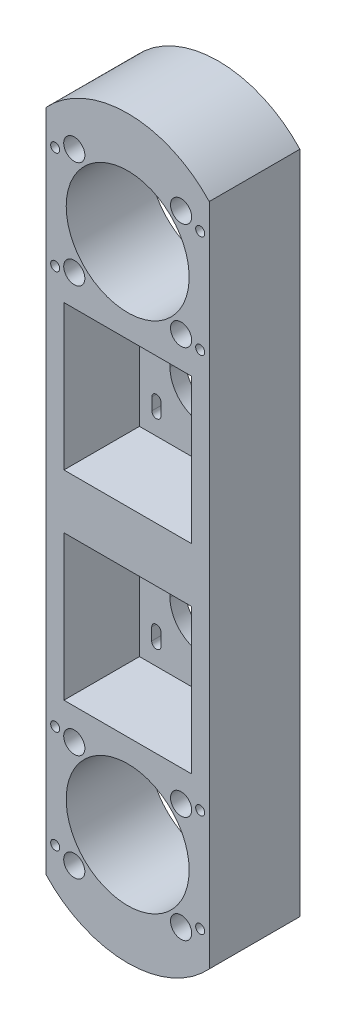
from build123d import *

# Parameters (mm, degrees)
SKETCH_1_W                = 54
SKETCH_1_H                = 220
EXTRUDE_1_DEPTH           = 30
SKETCH_2_W                = 42.2
SKETCH_2_H                = 48
CUT_EXTRUDE_1_DEPTH       = 25
SKETCH_3_W                = 42.2
SKETCH_3_H                = 48
CUT_EXTRUDE_2_DEPTH       = 25
CUT_EXTRUDE_3_DEPTH       = 6
CUT_EXTRUDE_13_DEPTH      = 6
SKETCH_18_W               = 42.7
SKETCH_18_H               = 42.7
CUT_EXTRUDE_9_DEPTH       = 2.5
SKETCH_9_R                = 20.35
SKETCH_9_R_2              = 2.1
CUT_EXTRUDE_4_DEPTH       = 28.5
SKETCH_16_W               = 42.7
SKETCH_16_H               = 42.7
CUT_EXTRUDE_7_DEPTH       = 2.5
SKETCH_13_R               = 20.35
SKETCH_13_R_2             = 2.1
CUT_EXTRUDE_6_DEPTH       = 28.5
EXTRUDE_3_DEPTH           = 30
CUT_EXTRUDE_8_REACH       = 32
SKETCH_17_R               = 1.5
SKETCH_21_R               = 3.5
CUT_EXTRUDE_11_DEPTH      = 1
CUT_EXTRUDE_11_DEPTH_BACK = 7.5
EXTRUDE_4_DEPTH           = 30
SKETCH_29_R               = 3.5
CUT_EXTRUDE_15_DEPTH      = 7.5
CUT_EXTRUDE_16_REACH      = 32
SKETCH_30_R               = 1.5


with BuildPart() as part:
    # 草图1 → 凸台-拉伸1 (new body)
    with BuildSketch(Plane.XY):
        Rectangle(SKETCH_1_W, SKETCH_1_H)
    extrude(amount=EXTRUDE_1_DEPTH)

    # 草图2 → 切除-拉伸1 (cut)
    with BuildSketch(Plane.XY.offset(30)):
        with Locations((0, 33)):
            Rectangle(SKETCH_2_W, SKETCH_2_H)
    extrude(amount=-CUT_EXTRUDE_1_DEPTH, mode=Mode.SUBTRACT)

    # 草图3 → 切除-拉伸2 (cut)
    with BuildSketch(Plane(origin=(0, 0, 30), x_dir=(-1, 0, 0), z_dir=(0, 0, -1))):
        with Locations((0, -33)):
            Rectangle(SKETCH_3_W, SKETCH_3_H)
    extrude(amount=CUT_EXTRUDE_2_DEPTH, mode=Mode.SUBTRACT)

    # 草图4 → 切除-拉伸3 (cut, through all)
    with BuildSketch(Plane.XY.offset(5)):
        with BuildLine():
            Line((11, 31), (11, 35))
            ThreePointArc((11, 35), (0, 46), (-11, 35))
            Line((-11, 35), (-11, 31))
            ThreePointArc((-11, 31), (0, 20), (11, 31))
        make_face()
        with BuildLine():
            Line((-14, 46.5), (-14, 50.5))
            ThreePointArc((-14, 50.5), (-15.5, 52), (-17, 50.5))
            Line((-17, 50.5), (-17, 46.5))
            ThreePointArc((-17, 46.5), (-15.5, 45), (-14, 46.5))
        make_face()
        with BuildLine():
            ThreePointArc((17, 50.5), (15.5, 52), (14, 50.5))
            Line((14, 50.5), (14, 46.5))
            ThreePointArc((14, 46.5), (15.5, 45), (17, 46.5))
            Line((17, 46.5), (17, 50.5))
        make_face()
        with BuildLine():
            Line((14, 19.5), (14, 15.5))
            ThreePointArc((14, 15.5), (15.5, 14), (17, 15.5))
            Line((17, 15.5), (17, 19.5))
            ThreePointArc((17, 19.5), (15.5, 21), (14, 19.5))
        make_face()
        with BuildLine():
            ThreePointArc((-17, 15.5), (-15.5, 14), (-14, 15.5))
            Line((-14, 15.5), (-14, 19.5))
            ThreePointArc((-14, 19.5), (-15.5, 21), (-17, 19.5))
            Line((-17, 19.5), (-17, 15.5))
        make_face()
    extrude(amount=-CUT_EXTRUDE_3_DEPTH, mode=Mode.SUBTRACT)

    # 草图26 → 切除-拉伸13 (cut, through all)
    with BuildSketch(Plane.XY.offset(5)):
        with BuildLine():
            Line((11, -31), (11, -35))
            ThreePointArc((11, -35), (0, -46), (-11, -35))
            Line((-11, -35), (-11, -31))
            ThreePointArc((-11, -31), (0, -20), (11, -31))
        make_face()
        with BuildLine():
            Line((-13.95, -15.5), (-13.95, -19.5))
            ThreePointArc((-13.95, -19.5), (-15.5, -21.05), (-17.05, -19.5))
            Line((-17.05, -19.5), (-17.05, -15.5))
            ThreePointArc((-17.05, -15.5), (-15.5, -13.95), (-13.95, -15.5))
        make_face()
        with BuildLine():
            Line((-13.95, -50.5), (-13.95, -46.5))
            ThreePointArc((-13.95, -46.5), (-15.5, -44.95), (-17.05, -46.5))
            Line((-17.05, -46.5), (-17.05, -50.5))
            ThreePointArc((-17.05, -50.5), (-15.5, -52.05), (-13.95, -50.5))
        make_face()
        with BuildLine():
            Line((13.95, -50.5), (13.95, -46.5))
            ThreePointArc((13.95, -46.5), (15.5, -44.95), (17.05, -46.5))
            Line((17.05, -46.5), (17.05, -50.5))
            ThreePointArc((17.05, -50.5), (15.5, -52.05), (13.95, -50.5))
        make_face()
        with BuildLine():
            Line((13.95, -15.5), (13.95, -19.5))
            ThreePointArc((13.95, -19.5), (15.5, -21.05), (17.05, -19.5))
            Line((17.05, -19.5), (17.05, -15.5))
            ThreePointArc((17.05, -15.5), (15.5, -13.95), (13.95, -15.5))
        make_face()
    extrude(amount=-CUT_EXTRUDE_13_DEPTH, mode=Mode.SUBTRACT)

    # 草图18 → 切除-拉伸9 (cut)
    with BuildSketch(Plane.XY):
        with Locations((0, -85)):
            Rectangle(SKETCH_18_W, SKETCH_18_H)
    extrude(amount=CUT_EXTRUDE_9_DEPTH, mode=Mode.SUBTRACT)

    # 草图9 → 切除-拉伸4 (cut, through all)
    with BuildSketch(Plane.XY.offset(2.5)):
        with Locations((0, -85)):
            Circle(SKETCH_9_R)
        with Locations((-17.67766953, -67.32233047)):
            Circle(SKETCH_9_R_2)
        with Locations((17.67766953, -67.32233047)):
            Circle(SKETCH_9_R_2)
        with Locations((17.67766953, -102.67766953)):
            Circle(SKETCH_9_R_2)
        with Locations((-17.67766953, -102.67766953)):
            Circle(SKETCH_9_R_2)
    extrude(amount=CUT_EXTRUDE_4_DEPTH, mode=Mode.SUBTRACT)

    # 草图16 → 切除-拉伸7 (cut)
    with BuildSketch(Plane.XY):
        with Locations((0, 85)):
            Rectangle(SKETCH_16_W, SKETCH_16_H)
    extrude(amount=CUT_EXTRUDE_7_DEPTH, mode=Mode.SUBTRACT)

    # 草图13 → 切除-拉伸6 (cut, through all)
    with BuildSketch(Plane(origin=(0, 0, 2.5), x_dir=(-1, 0, 0), z_dir=(0, 0, -1))):
        with Locations((0, 85)):
            Circle(SKETCH_13_R)
        with Locations((-17.67766953, 102.67766953)):
            Circle(SKETCH_13_R_2)
        with Locations((17.67766953, 102.67766953)):
            Circle(SKETCH_13_R_2)
        with Locations((17.67766953, 67.32233047)):
            Circle(SKETCH_13_R_2)
        with Locations((-17.67766953, 67.32233047)):
            Circle(SKETCH_13_R_2)
    extrude(amount=-CUT_EXTRUDE_6_DEPTH, mode=Mode.SUBTRACT)

    # 草图15 → 凸台-拉伸3 (add)
    with BuildSketch(Plane(origin=(0, 0, 0), x_dir=(-1, 0, 0), z_dir=(0, 0, -1))):
        with BuildLine():
            Line((-27, 110), (27, 110))
            ThreePointArc((27, 110), (0, 121.796738986), (-27, 110))
        make_face()
    extrude(amount=-EXTRUDE_3_DEPTH)

    # 草图17 → 切除-拉伸8 (cut, up to next)
    with BuildSketch(Plane(origin=(0, 0, 0), x_dir=(-1, 0, 0), z_dir=(0, 0, -1)), mode=Mode.PRIVATE) as cut_extrude_8_sk1:
        with Locations((-24, 100)):
            Circle(SKETCH_17_R)
    cut_extrude_8_tool1 = extrude(cut_extrude_8_sk1.sketch, amount=-CUT_EXTRUDE_8_REACH, mode=Mode.PRIVATE) & part.part
    add(cut_extrude_8_tool1.solids().sort_by_distance((24, 100, 0))[0], mode=Mode.SUBTRACT)
    # 草图17 → 切除-拉伸8 (cut, up to next)
    with BuildSketch(Plane(origin=(0, 0, 0), x_dir=(-1, 0, 0), z_dir=(0, 0, -1)), mode=Mode.PRIVATE) as cut_extrude_8_sk2:
        with Locations((24, 100)):
            Circle(SKETCH_17_R)
    cut_extrude_8_tool2 = extrude(cut_extrude_8_sk2.sketch, amount=-CUT_EXTRUDE_8_REACH, mode=Mode.PRIVATE) & part.part
    add(cut_extrude_8_tool2.solids().sort_by_distance((-24, 100, 0))[0], mode=Mode.SUBTRACT)
    # 草图17 → 切除-拉伸8 (cut, up to next)
    with BuildSketch(Plane(origin=(0, 0, 0), x_dir=(-1, 0, 0), z_dir=(0, 0, -1)), mode=Mode.PRIVATE) as cut_extrude_8_sk3:
        with Locations((24, 66)):
            Circle(SKETCH_17_R)
    cut_extrude_8_tool3 = extrude(cut_extrude_8_sk3.sketch, amount=-CUT_EXTRUDE_8_REACH, mode=Mode.PRIVATE) & part.part
    add(cut_extrude_8_tool3.solids().sort_by_distance((-24, 66, 0))[0], mode=Mode.SUBTRACT)
    # 草图17 → 切除-拉伸8 (cut, up to next)
    with BuildSketch(Plane(origin=(0, 0, 0), x_dir=(-1, 0, 0), z_dir=(0, 0, -1)), mode=Mode.PRIVATE) as cut_extrude_8_sk4:
        with Locations((-24, 66)):
            Circle(SKETCH_17_R)
    cut_extrude_8_tool4 = extrude(cut_extrude_8_sk4.sketch, amount=-CUT_EXTRUDE_8_REACH, mode=Mode.PRIVATE) & part.part
    add(cut_extrude_8_tool4.solids().sort_by_distance((24, 66, 0))[0], mode=Mode.SUBTRACT)

    # 草图21 → 切除-拉伸11 (cut, two sides)
    with BuildSketch(Plane.XY.offset(30)) as cut_extrude_11_sk:
        with Locations((-17.67766953, 102.67766953)):
            Circle(SKETCH_21_R)
        with Locations((17.67766953, 102.67766953)):
            Circle(SKETCH_21_R)
        with Locations((17.67766953, 67.32233047)):
            Circle(SKETCH_21_R)
        with Locations((-17.67766953, 67.32233047)):
            Circle(SKETCH_21_R)
    extrude(amount=CUT_EXTRUDE_11_DEPTH, mode=Mode.SUBTRACT)
    extrude(cut_extrude_11_sk.sketch, amount=-CUT_EXTRUDE_11_DEPTH_BACK, mode=Mode.SUBTRACT)

    # 草图28 → 凸台-拉伸4 (add)
    with BuildSketch(Plane.XY.offset(30)):
        with BuildLine():
            Line((-27, -110), (27, -110))
            ThreePointArc((27, -110), (0, -121.795200461), (-27, -110))
        make_face()
    extrude(amount=-EXTRUDE_4_DEPTH)

    # 草图29 → 切除-拉伸15 (cut)
    with BuildSketch(Plane.XY.offset(30)):
        with Locations((-17.67766953, -67.32233047)):
            Circle(SKETCH_29_R)
        with Locations((17.67766953, -67.32233047)):
            Circle(SKETCH_29_R)
        with Locations((17.67766953, -102.67766953)):
            Circle(SKETCH_29_R)
        with Locations((-17.67766953, -102.67766953)):
            Circle(SKETCH_29_R)
    extrude(amount=-CUT_EXTRUDE_15_DEPTH, mode=Mode.SUBTRACT)

    # 草图30 → 切除-拉伸16 (cut, up to next)
    with BuildSketch(Plane(origin=(0, 0, 0), x_dir=(-1, 0, 0), z_dir=(0, 0, -1)), mode=Mode.PRIVATE) as cut_extrude_16_sk1:
        with Locations((-24, -100)):
            Circle(SKETCH_30_R)
    cut_extrude_16_tool1 = extrude(cut_extrude_16_sk1.sketch, amount=-CUT_EXTRUDE_16_REACH, mode=Mode.PRIVATE) & part.part
    add(cut_extrude_16_tool1.solids().sort_by_distance((24, -100, 0))[0], mode=Mode.SUBTRACT)
    # 草图30 → 切除-拉伸16 (cut, up to next)
    with BuildSketch(Plane(origin=(0, 0, 0), x_dir=(-1, 0, 0), z_dir=(0, 0, -1)), mode=Mode.PRIVATE) as cut_extrude_16_sk2:
        with Locations((-24, -66)):
            Circle(SKETCH_30_R)
    cut_extrude_16_tool2 = extrude(cut_extrude_16_sk2.sketch, amount=-CUT_EXTRUDE_16_REACH, mode=Mode.PRIVATE) & part.part
    add(cut_extrude_16_tool2.solids().sort_by_distance((24, -66, 0))[0], mode=Mode.SUBTRACT)
    # 草图30 → 切除-拉伸16 (cut, up to next)
    with BuildSketch(Plane(origin=(0, 0, 0), x_dir=(-1, 0, 0), z_dir=(0, 0, -1)), mode=Mode.PRIVATE) as cut_extrude_16_sk3:
        with Locations((24, -66)):
            Circle(SKETCH_30_R)
    cut_extrude_16_tool3 = extrude(cut_extrude_16_sk3.sketch, amount=-CUT_EXTRUDE_16_REACH, mode=Mode.PRIVATE) & part.part
    add(cut_extrude_16_tool3.solids().sort_by_distance((-24, -66, 0))[0], mode=Mode.SUBTRACT)
    # 草图30 → 切除-拉伸16 (cut, up to next)
    with BuildSketch(Plane(origin=(0, 0, 0), x_dir=(-1, 0, 0), z_dir=(0, 0, -1)), mode=Mode.PRIVATE) as cut_extrude_16_sk4:
        with Locations((24, -100)):
            Circle(SKETCH_30_R)
    cut_extrude_16_tool4 = extrude(cut_extrude_16_sk4.sketch, amount=-CUT_EXTRUDE_16_REACH, mode=Mode.PRIVATE) & part.part
    add(cut_extrude_16_tool4.solids().sort_by_distance((-24, -100, 0))[0], mode=Mode.SUBTRACT)


solid = part.part
